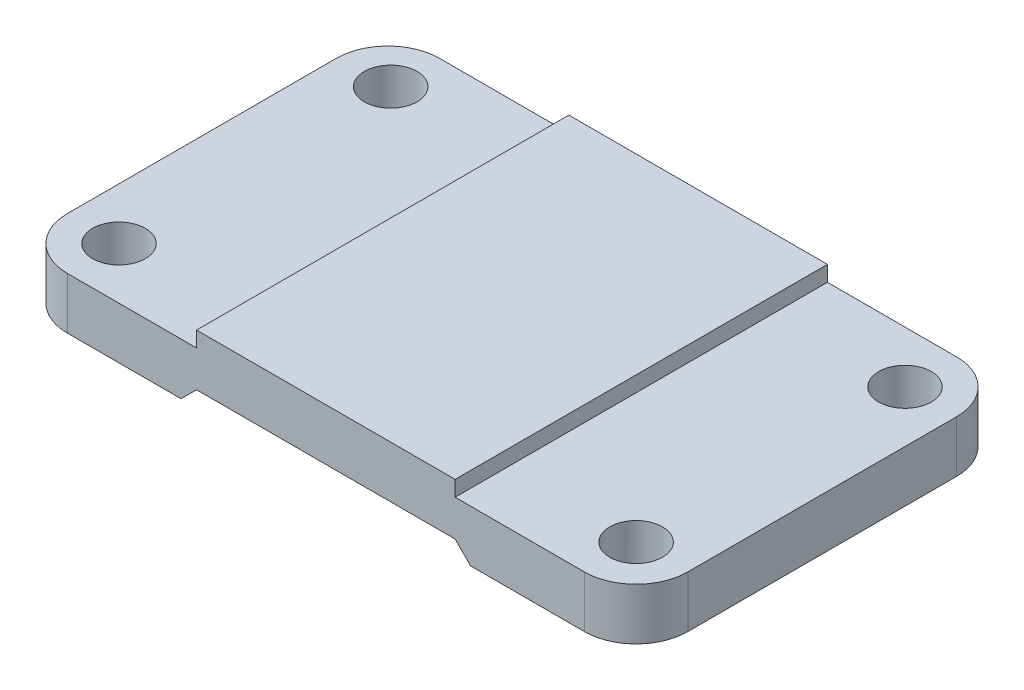
from build123d import *

# Parameters (mm, degrees)
SKETCH1_W              = 120
SKETCH1_H              = 72
BOSS_EXTRUDE1_DEPTH    = 10
FILLET1_R              = 10
M12_TAPPED_HOLE1_D     = 10.2
M12_TAPPED_HOLE1_DEPTH = 10
SKETCH4_W              = 50
SKETCH4_H              = 72
BOSS_EXTRUDE2_DEPTH    = 3
CUT_EXTRUDE1_DEPTH     = 73


with BuildPart() as part:
    # Sketch1 → Boss-Extrude1 (new body)
    with BuildSketch(Plane(origin=(0, 0, 0), x_dir=(1, 0, 0), z_dir=(0, 1, 0))):
        Rectangle(SKETCH1_W, SKETCH1_H)
    extrude(amount=BOSS_EXTRUDE1_DEPTH)

    # Fillet1
    fillet1_edges = [part.edges().sort_by_distance(p)[0] for p in [
        (60, 5, 36),
        (-60, 5, 36),
        (-60, 5, -36),
        (60, 5, -36),
    ]]
    fillet(fillet1_edges, radius=FILLET1_R)

    # M12 Tapped Hole1
    with Locations(Plane(origin=(0, 10, 0), x_dir=(1, 0, 0), z_dir=(0, 1, 0))):
        with Locations((0, 43.37107415), (50, -26), (50, 26), (-50, 26.540508062), (-50, -26)):
            Hole(M12_TAPPED_HOLE1_D / 2, depth=M12_TAPPED_HOLE1_DEPTH)

    # Sketch4 → Boss-Extrude2 (add)
    with BuildSketch(Plane(origin=(0, 10, 0), x_dir=(1, 0, 0), z_dir=(0, 1, 0))):
        Rectangle(SKETCH4_W, SKETCH4_H)
    extrude(amount=BOSS_EXTRUDE2_DEPTH)

    # Sketch5 → Cut-Extrude1 (cut, through all)
    with BuildSketch(Plane.XY.offset(36)):
        Polygon((-28, 0), (-25, 3), (25, 3), (28, 0), align=None)
    extrude(amount=-CUT_EXTRUDE1_DEPTH, mode=Mode.SUBTRACT)


solid = part.part
